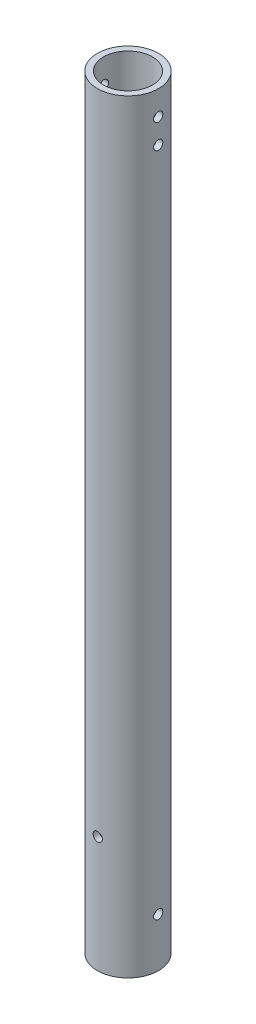
from build123d import *

# Parameters (mm, degrees)
SKETCH1_R                      = 10
SKETCH1_R_2                    = 8
BOSS_EXTRUDE1_DEPTH            = 125
CUT_EXTRUDE1_REACH             = 12
SKETCH2_R                      = 1.5
CUT_EXTRUDE1_DIRECTION_2_REACH = 12
CUT_EXTRUDE2_REACH             = 12
SKETCH3_R                      = 1.5
CUT_EXTRUDE2_DIRECTION_2_REACH = 12
CUT_EXTRUDE3_REACH             = 12
SKETCH4_R                      = 1.5
CUT_EXTRUDE3_DIRECTION_2_REACH = 12


with BuildPart() as part:
    # Sketch1 → Boss-Extrude1 (new body, symmetric)
    with BuildSketch(Plane(origin=(0, 0, 0), x_dir=(1, 0, 0), z_dir=(0, 1, 0))):
        Circle(SKETCH1_R)
        Circle(SKETCH1_R_2, mode=Mode.SUBTRACT)
    extrude(amount=BOSS_EXTRUDE1_DEPTH, both=True)

    # Sketch2 → Cut-Extrude1 (cut, up to next)
    with BuildSketch(Plane(origin=(0, 0, 0), x_dir=(0, 0, -1), z_dir=(1, 0, 0)), mode=Mode.PRIVATE) as cut_extrude1_sk1:
        with Locations((0, 117)):
            Circle(SKETCH2_R)
    cut_extrude1_tool1 = extrude(cut_extrude1_sk1.sketch, amount=-CUT_EXTRUDE1_REACH, mode=Mode.PRIVATE) & part.part
    add(cut_extrude1_tool1.solids().sort_by_distance((0, 117, 0))[0], mode=Mode.SUBTRACT)
    # Sketch2 → Cut-Extrude1 (cut, up to next)
    with BuildSketch(Plane(origin=(0, 0, 0), x_dir=(0, 0, -1), z_dir=(1, 0, 0)), mode=Mode.PRIVATE) as cut_extrude1_sk2:
        with Locations((0, 109)):
            Circle(SKETCH2_R)
    cut_extrude1_tool2 = extrude(cut_extrude1_sk2.sketch, amount=-CUT_EXTRUDE1_REACH, mode=Mode.PRIVATE) & part.part
    add(cut_extrude1_tool2.solids().sort_by_distance((0, 109, 0))[0], mode=Mode.SUBTRACT)

    # Sketch2 → Cut-Extrude1 direction 2 (cut, up to next)
    with BuildSketch(Plane(origin=(0, 0, 0), x_dir=(0, 0, -1), z_dir=(1, 0, 0)), mode=Mode.PRIVATE) as cut_extrude1_direction_2_sk1:
        with Locations((0, 117)):
            Circle(SKETCH2_R)
    cut_extrude1_direction_2_tool1 = extrude(cut_extrude1_direction_2_sk1.sketch, amount=CUT_EXTRUDE1_DIRECTION_2_REACH, mode=Mode.PRIVATE) & part.part
    add(cut_extrude1_direction_2_tool1.solids().sort_by_distance((0, 117, 0))[0], mode=Mode.SUBTRACT)
    # Sketch2 → Cut-Extrude1 direction 2 (cut, up to next)
    with BuildSketch(Plane(origin=(0, 0, 0), x_dir=(0, 0, -1), z_dir=(1, 0, 0)), mode=Mode.PRIVATE) as cut_extrude1_direction_2_sk2:
        with Locations((0, 109)):
            Circle(SKETCH2_R)
    cut_extrude1_direction_2_tool2 = extrude(cut_extrude1_direction_2_sk2.sketch, amount=CUT_EXTRUDE1_DIRECTION_2_REACH, mode=Mode.PRIVATE) & part.part
    add(cut_extrude1_direction_2_tool2.solids().sort_by_distance((0, 109, 0))[0], mode=Mode.SUBTRACT)

    # Sketch3 → Cut-Extrude2 (cut, up to next)
    with BuildSketch(Plane.XY, mode=Mode.PRIVATE) as cut_extrude2_sk1:
        with Locations((0, -87)):
            Circle(SKETCH3_R)
    cut_extrude2_tool1 = extrude(cut_extrude2_sk1.sketch, amount=-CUT_EXTRUDE2_REACH, mode=Mode.PRIVATE) & part.part
    add(cut_extrude2_tool1.solids().sort_by_distance((0, -87, 0))[0], mode=Mode.SUBTRACT)

    # Sketch3 → Cut-Extrude2 direction 2 (cut, up to next)
    with BuildSketch(Plane.XY, mode=Mode.PRIVATE) as cut_extrude2_direction_2_sk1:
        with Locations((0, -87)):
            Circle(SKETCH3_R)
    cut_extrude2_direction_2_tool1 = extrude(cut_extrude2_direction_2_sk1.sketch, amount=CUT_EXTRUDE2_DIRECTION_2_REACH, mode=Mode.PRIVATE) & part.part
    add(cut_extrude2_direction_2_tool1.solids().sort_by_distance((0, -87, 0))[0], mode=Mode.SUBTRACT)

    # Sketch4 → Cut-Extrude3 (cut, up to next)
    with BuildSketch(Plane(origin=(0, 0, 0), x_dir=(0, 0, -1), z_dir=(1, 0, 0)), mode=Mode.PRIVATE) as cut_extrude3_sk1:
        with Locations((0, -109)):
            Circle(SKETCH4_R)
    cut_extrude3_tool1 = extrude(cut_extrude3_sk1.sketch, amount=-CUT_EXTRUDE3_REACH, mode=Mode.PRIVATE) & part.part
    add(cut_extrude3_tool1.solids().sort_by_distance((0, -109, 0))[0], mode=Mode.SUBTRACT)

    # Sketch4 → Cut-Extrude3 direction 2 (cut, up to next)
    with BuildSketch(Plane(origin=(0, 0, 0), x_dir=(0, 0, -1), z_dir=(1, 0, 0)), mode=Mode.PRIVATE) as cut_extrude3_direction_2_sk1:
        with Locations((0, -109)):
            Circle(SKETCH4_R)
    cut_extrude3_direction_2_tool1 = extrude(cut_extrude3_direction_2_sk1.sketch, amount=CUT_EXTRUDE3_DIRECTION_2_REACH, mode=Mode.PRIVATE) & part.part
    add(cut_extrude3_direction_2_tool1.solids().sort_by_distance((0, -109, 0))[0], mode=Mode.SUBTRACT)


solid = part.part
